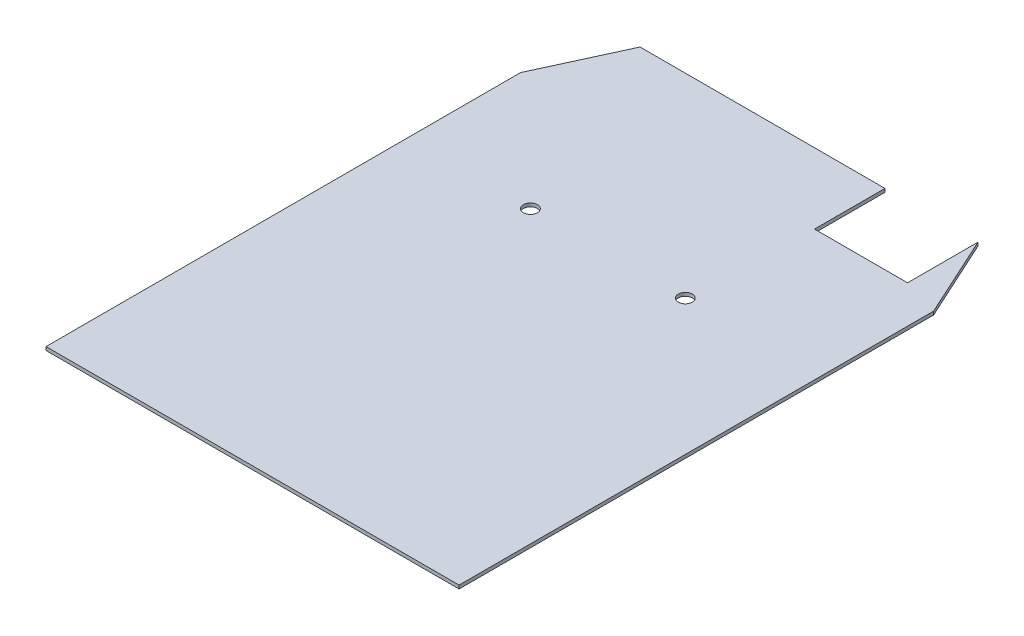
from build123d import *

# Parameters (mm, degrees)
BOSS_EXTRUDE1_DEPTH = 1.5875
SKETCH2_W           = 192.0875
SKETCH2_H           = 15.875
CUT_EXTRUDE1_DEPTH  = 1.5875
SKETCH4_R           = 3.2639
CUT_EXTRUDE2_DEPTH  = 9.906
SKETCH5_W           = 250.81556442
SKETCH5_H           = 138.767374129
CUT_EXTRUDE3_DEPTH  = 125.222


with BuildPart() as part:
    # Sketch1 → Boss-Extrude1 (new body)
    with BuildSketch(Plane(origin=(0, 0, 0), x_dir=(1, 0, 0), z_dir=(0, 1, 0))):
        Polygon((-96.04375, 177.8), (35.321875, 177.8), (35.321875, 145.036189145), (78.58125, 145.036189145), (78.58125, 177.8), (96.04375, 177.8), (96.04375, -177.8), (-96.04375, -177.8), align=None)
    extrude(amount=BOSS_EXTRUDE1_DEPTH)

    # Sketch2 → Cut-Extrude1 (cut)
    with BuildSketch(Plane(origin=(0, 1.5875, 0), x_dir=(1, 0, 0), z_dir=(0, 1, 0))):
        with Locations((0, -88.9)):
            Rectangle(SKETCH2_W, SKETCH2_H)
        Polygon((-78.58125, 177.8), (-96.04375, 139.7), (-96.04375, 177.8), align=None)
        Polygon((96.04375, 139.7), (78.58125, 177.8), (96.04375, 177.8), align=None)
    extrude(amount=-CUT_EXTRUDE1_DEPTH, mode=Mode.SUBTRACT)

    # Sketch4 → Cut-Extrude2 (cut)
    with BuildSketch(Plane(origin=(0, 1.5875, 0), x_dir=(1, 0, 0), z_dir=(0, 1, 0))):
        with Locations((33.07715, 87.20455)):
            Circle(SKETCH4_R)
        with Locations((-38.93185, 87.20455)):
            Circle(SKETCH4_R)
    extrude(amount=-CUT_EXTRUDE2_DEPTH, mode=Mode.SUBTRACT)

    # Sketch5 → Cut-Extrude3 (cut)
    with BuildSketch(Plane(origin=(0, 1.5875, 0), x_dir=(1, 0, 0), z_dir=(0, 1, 0))):
        with Locations((-21.956348657, -157.127502405)):
            Rectangle(SKETCH5_W, SKETCH5_H)
    extrude(amount=-CUT_EXTRUDE3_DEPTH, mode=Mode.SUBTRACT)


solid = part.part
